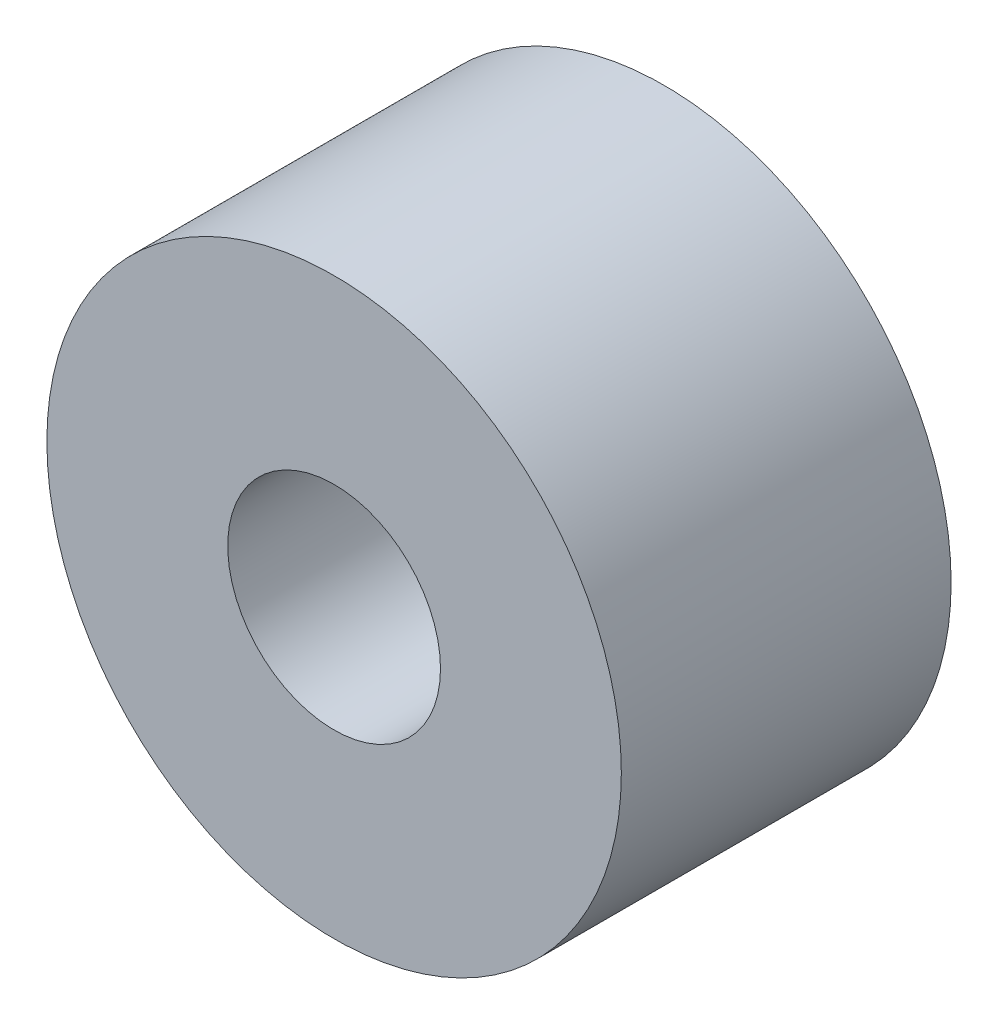
from build123d import *

# Parameters (mm, degrees)
SKETCH1_R           = 8.5725
SKETCH1_R_2         = 3.175
BOSS_EXTRUDE1_DEPTH = 9.8425


with BuildPart() as part:
    # Sketch1 → Boss-Extrude1 (new body)
    with BuildSketch(Plane.XY):
        Circle(SKETCH1_R)
        Circle(SKETCH1_R_2, mode=Mode.SUBTRACT)
    extrude(amount=BOSS_EXTRUDE1_DEPTH)


solid = part.part
